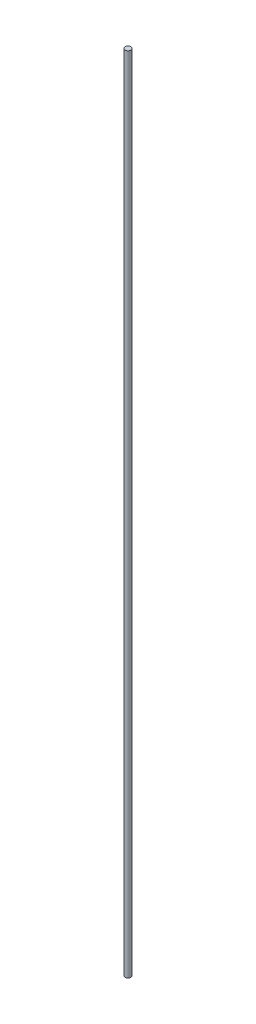
from build123d import *

# Parameters (mm, degrees)
SKETCH1_R           = 0.5
BOSS_EXTRUDE1_DEPTH = 136.17


with BuildPart() as part:
    # Sketch1 → Boss-Extrude1 (new body)
    with BuildSketch(Plane(origin=(0, 0, 0), x_dir=(1, 0, 0), z_dir=(0, 1, 0))):
        Circle(SKETCH1_R)
    extrude(amount=BOSS_EXTRUDE1_DEPTH)


solid = part.part
